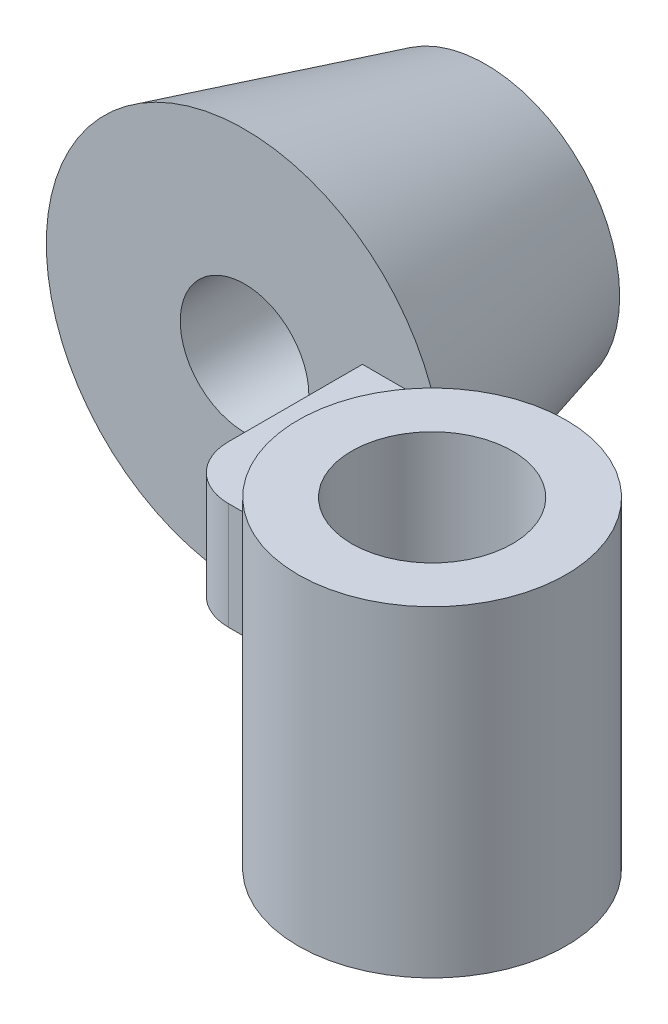
from build123d import *

# Parameters (mm, degrees)
SKETCH3_W                = 10
SKETCH3_H                = 25
SKETCH3_H_2              = 10
BOSS_EXTRUDE1_DEPTH      = 10
FILLET1_R                = 6
FILLET2_R                = 10
SKETCH4_R                = 15
CUT_EXTRUDE1_DEPTH       = 48
SKETCH4_3_R              = 25
SKETCH4_3_R_2            = 15
BOSS_EXTRUDE2_DEPTH      = 20
BOSS_EXTRUDE2_DEPTH_BACK = 40


with BuildPart() as part:
    # Sketch1 → Revolve1 (revolve)
    with BuildSketch(Plane(origin=(0, 0, 0), x_dir=(1, 0, 0), z_dir=(0, 1, 0))):
        Polygon((12, 45), (0, 0), (25, 0), (25, 45), align=None)
    revolve(axis=Axis((37, 0, 0), (0, 0, -1)))

    # Sketch3 → Boss-Extrude1 (add, symmetric)
    with BuildSketch(Plane(origin=(0, 0, 0), x_dir=(1, 0, 0), z_dir=(0, 1, 0))):
        with Locations((64, -12.5)):
            Rectangle(SKETCH3_W, SKETCH3_H)
        with Locations((64, -30)):
            Rectangle(SKETCH3_W, SKETCH3_H_2)
        Polygon((75.698729811, -25), (69, -25), (69, -35), (107, -35), (107, -25), align=None)
        Polygon((75.698729811, -25), (69, 0), (69, -25), align=None)
    extrude(amount=BOSS_EXTRUDE1_DEPTH, both=True)

    # Fillet1
    fillet1_edges = [part.edges().sort_by_distance(p)[0] for p in [
        (75.698729811, 0, 25),
    ]]
    fillet(fillet1_edges, radius=FILLET1_R)

    # Fillet2
    fillet2_edges = [part.edges().sort_by_distance(p)[0] for p in [
        (59, 0, 35),
    ]]
    fillet(fillet2_edges, radius=FILLET2_R)

    # Sketch4 → Cut-Extrude1 (cut, through all)
    with BuildSketch(Plane(origin=(0, 10, 0), x_dir=(1, 0, 0), z_dir=(0, 1, 0))):
        with Locations((107, -35)):
            Circle(SKETCH4_R)
    extrude(amount=-CUT_EXTRUDE1_DEPTH, mode=Mode.SUBTRACT)

    # Sketch4_3 → Boss-Extrude2 (add, two sides)
    with BuildSketch(Plane(origin=(0, 10, 0), x_dir=(1, 0, 0), z_dir=(0, 1, 0))) as boss_extrude2_sk:
        with Locations((107, -35)):
            Circle(SKETCH4_3_R)
        with Locations((107, -35)):
            Circle(SKETCH4_3_R_2, mode=Mode.SUBTRACT)
    extrude(amount=BOSS_EXTRUDE2_DEPTH)
    extrude(boss_extrude2_sk.sketch, amount=-BOSS_EXTRUDE2_DEPTH_BACK)


solid = part.part
